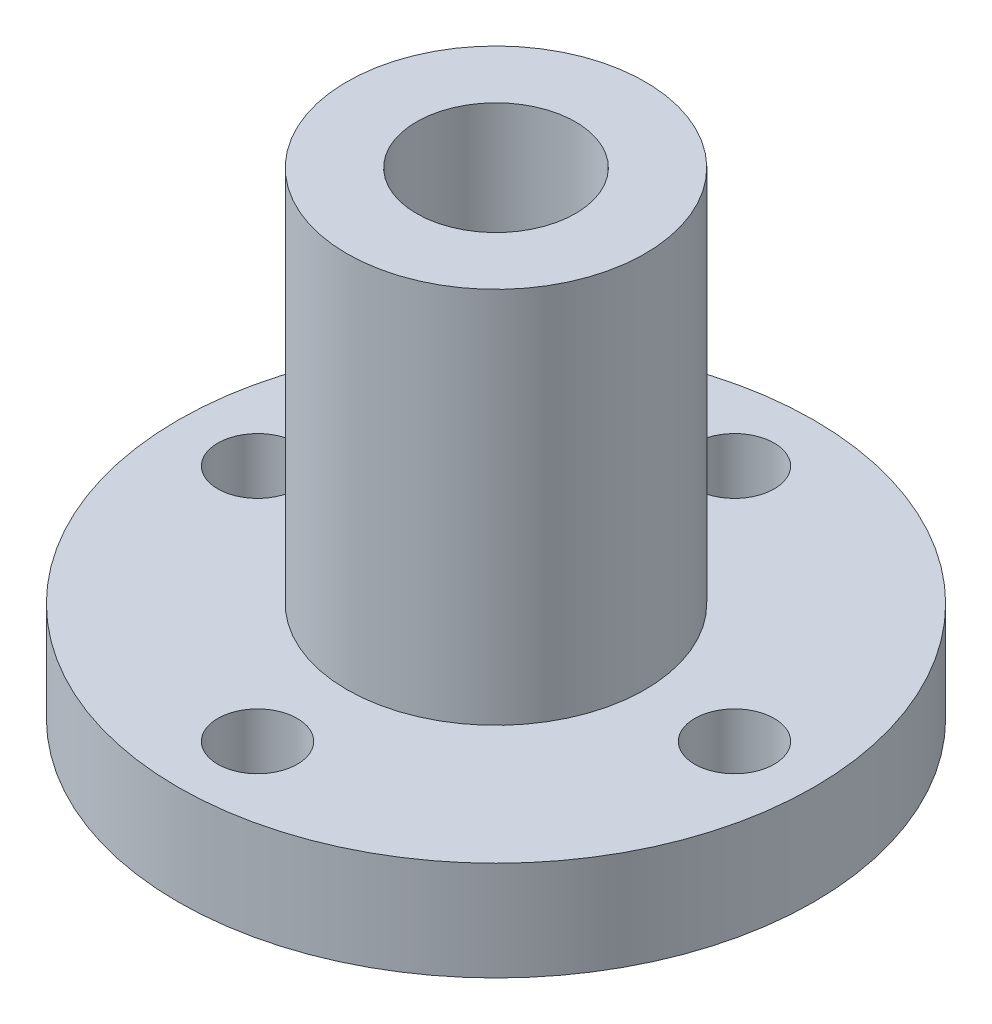
from build123d import *

# Parameters (mm, degrees)
SKETCH2_R           = 16
BOSS_EXTRUDE1_DEPTH = 5
SKETCH3_R           = 7.5
BOSS_EXTRUDE2_DEPTH = 19
SKETCH4_R           = 4
CUT_EXTRUDE1_DEPTH  = 50
SKETCH5_R           = 2
CUT_EXTRUDE2_DEPTH  = 50


with BuildPart() as part:
    # Sketch2 → Boss-Extrude1 (new body)
    with BuildSketch(Plane(origin=(0, 0, 0), x_dir=(1, 0, 0), z_dir=(0, 1, 0))):
        Circle(SKETCH2_R)
    extrude(amount=BOSS_EXTRUDE1_DEPTH)

    # Sketch3 → Boss-Extrude2 (add)
    with BuildSketch(Plane(origin=(0, 5, 0), x_dir=(1, 0, 0), z_dir=(0, 1, 0))):
        Circle(SKETCH3_R)
    extrude(amount=BOSS_EXTRUDE2_DEPTH)

    # Sketch4 → Cut-Extrude1 (cut)
    with BuildSketch(Plane(origin=(0, 24, 0), x_dir=(1, 0, 0), z_dir=(0, 1, 0))):
        Circle(SKETCH4_R)
    extrude(amount=-CUT_EXTRUDE1_DEPTH, mode=Mode.SUBTRACT)

    # Sketch5 → Cut-Extrude2 (cut)
    with BuildSketch(Plane(origin=(0, 5, 0), x_dir=(1, 0, 0), z_dir=(0, 1, 0))):
        with Locations((0, 12)):
            Circle(SKETCH5_R)
        with Locations((0, -12)):
            Circle(SKETCH5_R)
        with Locations((-12, 0)):
            Circle(SKETCH5_R)
        with Locations((12, 0)):
            Circle(SKETCH5_R)
    extrude(amount=-CUT_EXTRUDE2_DEPTH, mode=Mode.SUBTRACT)


solid = part.part
